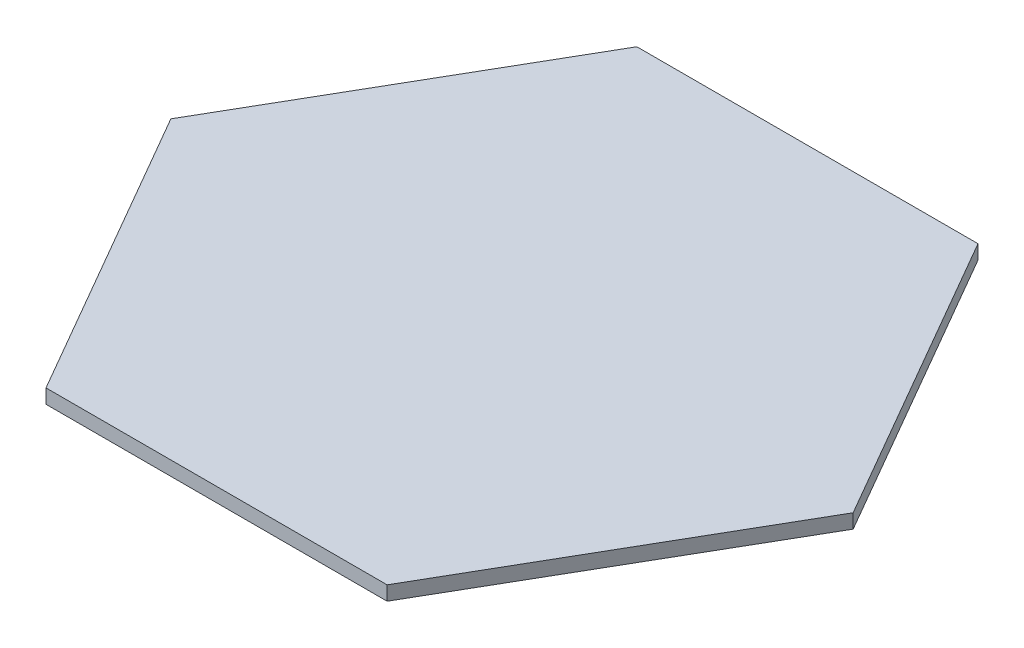
from build123d import *

# Parameters (mm, degrees)
BOSS_EXTRUDE1_DEPTH = 3.175


with BuildPart() as part:
    # Sketch1 → Boss-Extrude1 (new body)
    with BuildSketch(Plane(origin=(0, 0, 0), x_dir=(1, 0, 0), z_dir=(0, 1, 0))):
        Polygon((76.2, 0), (38.1, 65.991135768), (-38.1, 65.991135768), (-76.2, 0), (-38.1, -65.991135768), (38.1, -65.991135768), align=None)
    extrude(amount=BOSS_EXTRUDE1_DEPTH)


solid = part.part
